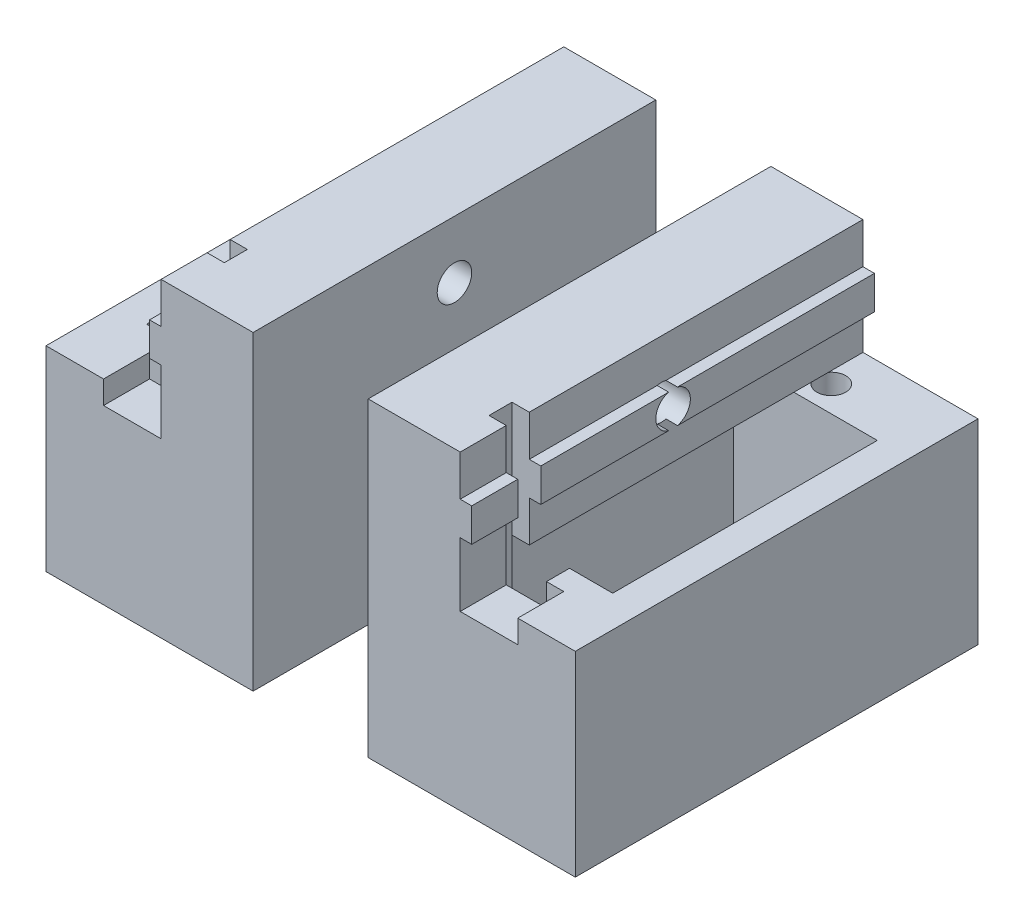
from build123d import *

# Parameters (mm, degrees)
SKETCH1_W             = 18
SKETCH1_H             = 17
MAIN_DEPTH            = 17.5
SKETCH2_R             = 1.25
FIXINGHOLE_DEPTH      = 18
SERVOSQUAREHOLE_DEPTH = 18
BOSS_EXTRUDE1_DEPTH   = 35
SKETCH5_R             = 1.5
CUT_EXTRUDE1_DEPTH    = 19
SKETCH6_W             = 5
SKETCH6_H             = 2
CUT_EXTRUDE2_DEPTH    = 28
SKETCH7_W             = 5
SKETCH7_H             = 2
CUT_EXTRUDE3_DEPTH    = 4


with BuildPart() as part:
    # Sketch1 → Main (new body, symmetric)
    with BuildSketch(Plane.XY):
        with Locations((0, 8.5)):
            Rectangle(SKETCH1_W, SKETCH1_H)
    extrude(amount=MAIN_DEPTH, both=True)

    # Sketch2 → FixingHole (cut, through all)
    with BuildSketch(Plane(origin=(0, 17, 0), x_dir=(1, 0, 0), z_dir=(0, 1, 0))):
        with Locations((0, 13.75)):
            Circle(SKETCH2_R)
    extrude(amount=-FIXINGHOLE_DEPTH, mode=Mode.SUBTRACT)

    # Sketch3 → ServoSquareHole (cut, through all)
    with BuildSketch(Plane(origin=(0, 17, 0), x_dir=(1, 0, 0), z_dir=(0, 1, 0))):
        Polygon((-6.25, 11.5), (6.25, 11.5), (6.25, -11.5), (2.5, -11.5), (2.5, -13.5), (-2.5, -13.5), (-2.5, -11.5), (-6.25, -11.5), align=None)
    extrude(amount=-SERVOSQUAREHOLE_DEPTH, mode=Mode.SUBTRACT)

    # Sketch4 → Boss-Extrude1 (add)
    with BuildSketch(Plane.XY.offset(17.5)):
        Polygon((9, 17), (9, 27), (1, 27), (1, 23.45), (0, 23.45), (0, 20.55), (1, 20.55), (1, 17), align=None)
    extrude(amount=-BOSS_EXTRUDE1_DEPTH)

    # Sketch5 → Cut-Extrude1 (cut, through all)
    with BuildSketch(Plane(origin=(9, 0, 0), x_dir=(0, 0, -1), z_dir=(1, 0, 0))):
        with Locations((0, 22)):
            Circle(SKETCH5_R)
    extrude(amount=-CUT_EXTRUDE1_DEPTH, mode=Mode.SUBTRACT)

    # Sketch6 → Cut-Extrude2 (cut, through all)
    with BuildSketch(Plane(origin=(0, 0, 0), x_dir=(-1, 0, 0), z_dir=(0, -1, 0))):
        with Locations((0, -12.5)):
            Rectangle(SKETCH6_W, SKETCH6_H)
    extrude(amount=-CUT_EXTRUDE2_DEPTH, mode=Mode.SUBTRACT)

    # Sketch7 → Cut-Extrude3 (cut)
    with BuildSketch(Plane.XY.offset(17.5)):
        with Locations((-1.5, 16)):
            Rectangle(SKETCH7_W, SKETCH7_H)
    extrude(amount=-CUT_EXTRUDE3_DEPTH, mode=Mode.SUBTRACT)


with BuildPart() as body_2:
    # Mirror1: mirrored copy
    add(part.part.mirror(Plane(origin=(14, 0, 0), x_dir=(0, 0, 1), z_dir=(1, 0, 0))))


solid = Compound([part.part, body_2.part])
